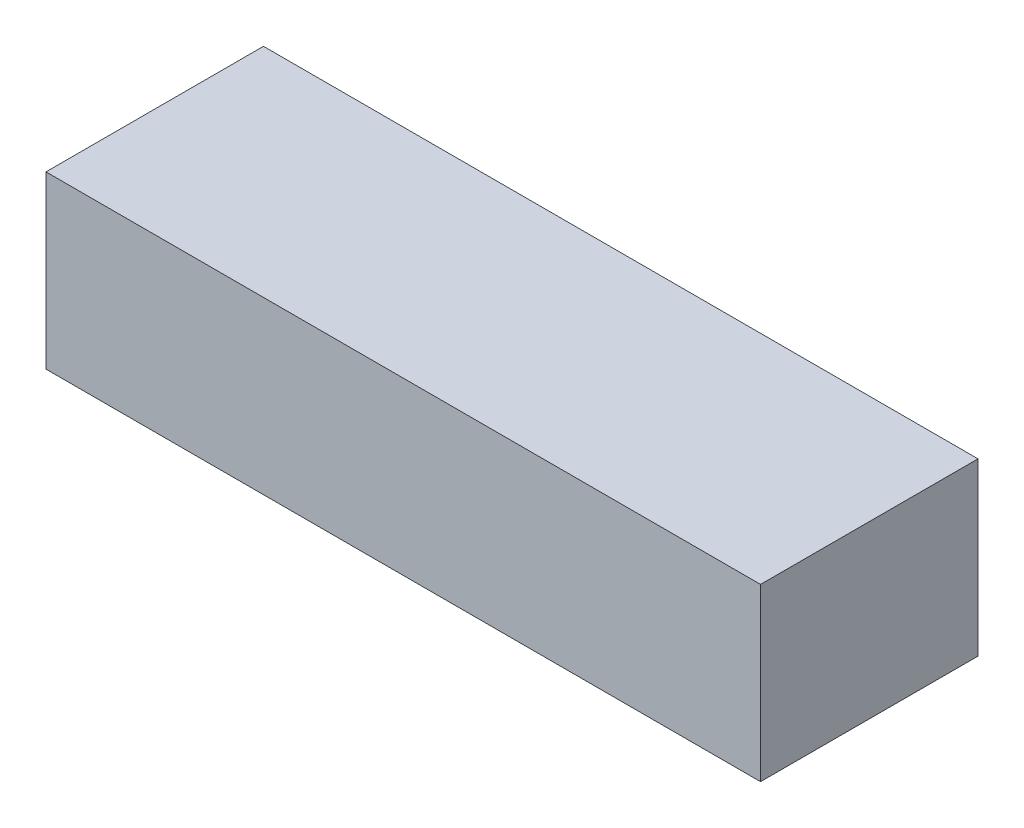
from build123d import *

# Parameters (mm, degrees)
SKETCH1_W           = 28
SKETCH1_H           = 22
BOSS_EXTRUDE1_DEPTH = 92


with BuildPart() as part:
    # Sketch1 → Boss-Extrude1 (new body)
    with BuildSketch(Plane(origin=(0, 0, 0), x_dir=(0, 0, -1), z_dir=(1, 0, 0))):
        Rectangle(SKETCH1_W, SKETCH1_H)
    extrude(amount=BOSS_EXTRUDE1_DEPTH)


solid = part.part
